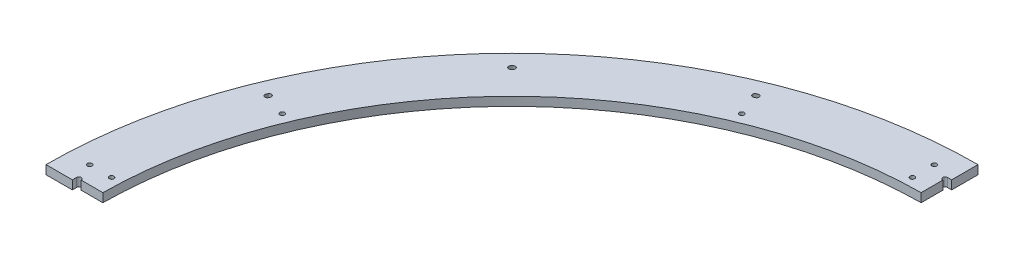
from build123d import *

# Parameters (mm, degrees)
BOSS_EXTRUDE1_DEPTH     = 12.7
SKETCH2_W               = 12.7
SKETCH2_H               = 38.133687951
SKETCH2_W_2             = 38.133687951
SKETCH2_H_2             = 12.7
CUT_EXTRUDE1_DEPTH      = 13.7
SKETCH3_R               = 3.429
CUT_EXTRUDE2_DEPTH      = 13.7
F_1_4_CLEARANCE_HOLE2_D = 6.7564
SKETCH8_W               = 674.6875
SKETCH8_H               = 674.6875
CUT_EXTRUDE4_DEPTH      = 13.7
SKETCH10_W              = 0.3175
SKETCH10_H              = 38.1
SKETCH10_W_2            = 38.1
SKETCH10_H_2            = 0.3175
CUT_EXTRUDE5_DEPTH      = 13.7
CUT_EXTRUDE6_DEPTH      = 13.7


with BuildPart() as part:
    # Sketch1 → Boss-Extrude1 (new body)
    with BuildSketch(Plane(origin=(0, 0, 0), x_dir=(1, 0, 0), z_dir=(0, 1, 0))):
        with BuildLine():
            Line((-598.4875, 0), (-674.6875, 0))
            ThreePointArc((-674.6875, 0), (0, 674.6875), (674.6875, 0))
            Line((674.6875, 0), (598.4875, 0))
            ThreePointArc((598.4875, 0), (0, 598.4875), (-598.4875, 0))
        make_face()
    extrude(amount=BOSS_EXTRUDE1_DEPTH)

    # Sketch2 → Cut-Extrude1 (cut, through all)
    with BuildSketch(Plane(origin=(0, 12.7, 0), x_dir=(1, 0, 0), z_dir=(0, 1, 0))):
        with Locations((0, 617.520656025)):
            Rectangle(SKETCH2_W, SKETCH2_H)
        with Locations((617.520656025, 0)):
            Rectangle(SKETCH2_W_2, SKETCH2_H_2)
        with Locations((0, -617.520656025)):
            Rectangle(SKETCH2_W, SKETCH2_H)
        with Locations((-617.520656025, 0)):
            Rectangle(SKETCH2_W_2, SKETCH2_H_2)
    extrude(amount=-CUT_EXTRUDE1_DEPTH, mode=Mode.SUBTRACT)

    # Sketch3 → Cut-Extrude2 (cut, through all)
    with BuildSketch(Plane(origin=(0, 12.7, 0), x_dir=(1, 0, 0), z_dir=(0, 1, 0))):
        with Locations((-6.35, 633.1585)):
            Circle(SKETCH3_R)
        with Locations((-633.1585, 6.35)):
            Circle(SKETCH3_R)
        with Locations((6.35, 633.1585)):
            Circle(SKETCH3_R)
        with Locations((633.1585, 6.35)):
            Circle(SKETCH3_R)
    extrude(amount=-CUT_EXTRUDE2_DEPTH, mode=Mode.SUBTRACT)

    # 1/4 Clearance Hole2 (through all)
    with Locations(Plane(origin=(0, 12.7, 0), x_dir=(1, 0, 0), z_dir=(0, 1, 0))):
        with Locations((-31.75, 642.9375), (-31.75, 611.1875), (-611.1875, 31.75), (-642.9375, 31.75), (-567.596939292, 235.106350216), (-235.106350216, 567.596939292)):
            Hole(F_1_4_CLEARANCE_HOLE2_D / 2)

    # Sketch8 → Cut-Extrude4 (cut, through all)
    with BuildSketch(Plane(origin=(0, 12.7, 0), x_dir=(1, 0, 0), z_dir=(0, 1, 0))):
        with Locations((337.34375, 337.34375)):
            Rectangle(SKETCH8_W, SKETCH8_H)
    extrude(amount=-CUT_EXTRUDE4_DEPTH, mode=Mode.SUBTRACT)

    # Sketch10 → Cut-Extrude5 (cut, through all)
    with BuildSketch(Plane(origin=(0, 12.7, 0), x_dir=(1, 0, 0), z_dir=(0, 1, 0))):
        with Locations((-0.15875, 655.6375)):
            Rectangle(SKETCH10_W, SKETCH10_H)
        with Locations((-655.6375, 0.15875)):
            Rectangle(SKETCH10_W_2, SKETCH10_H_2)
    extrude(amount=-CUT_EXTRUDE5_DEPTH, mode=Mode.SUBTRACT)

    # Sketch13 → Cut-Extrude6 (cut, through all)
    with BuildSketch(Plane(origin=(0, 12.7, 0), x_dir=(1, 0, 0), z_dir=(0, 1, 0))):
        with BuildLine():
            ThreePointArc((-602.990490798, 249.74984277), (-603.400029696, 248.75875888), (-603.807939635, 247.767003434))
            ThreePointArc((-603.807939635, 247.767003434), (-601.965070474, 243.359248479), (-597.55731552, 245.20211764))
            ThreePointArc((-597.55731552, 245.20211764), (-597.153628267, 246.183606427), (-596.748328919, 247.164430609))
            ThreePointArc((-596.748328919, 247.164430609), (-598.576703778, 251.578217629), (-602.990490798, 249.74984277))
        make_face()
        with BuildLine():
            ThreePointArc((-460.745442177, 462.261996567), (-461.504342318, 461.504342318), (-462.261996567, 460.745442177))
            ThreePointArc((-462.261996567, 460.745442177), (-462.254146876, 455.967952369), (-457.476657068, 455.97580206))
            ThreePointArc((-457.476657068, 455.97580206), (-456.726846061, 456.726846061), (-455.97580206, 457.476657068))
            ThreePointArc((-455.97580206, 457.476657068), (-455.967952369, 462.254146876), (-460.745442177, 462.261996567))
        make_face()
        with BuildLine():
            ThreePointArc((-247.767003434, 603.807939635), (-248.75875888, 603.400029696), (-249.74984277, 602.990490798))
            ThreePointArc((-249.74984277, 602.990490798), (-251.578217629, 598.576703778), (-247.164430609, 596.748328919))
            ThreePointArc((-247.164430609, 596.748328919), (-246.183606427, 597.153628267), (-245.20211764, 597.55731552))
            ThreePointArc((-245.20211764, 597.55731552), (-243.359248479, 601.965070474), (-247.767003434, 603.807939635))
        make_face()
    extrude(amount=-CUT_EXTRUDE6_DEPTH, mode=Mode.SUBTRACT)


solid = part.part
